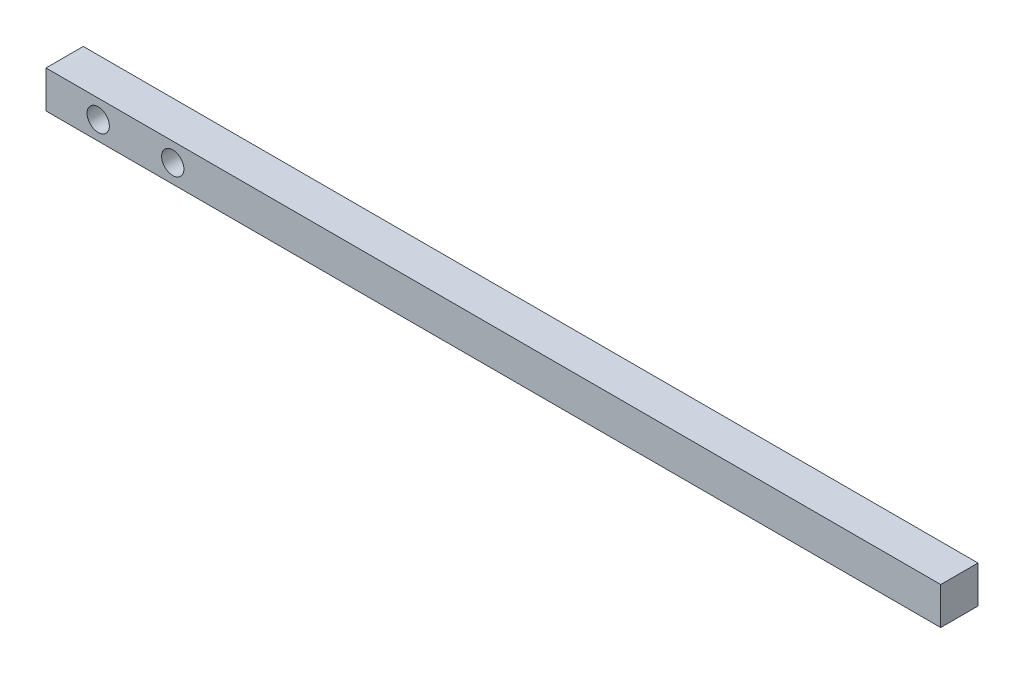
from build123d import *

# Parameters (mm, degrees)
SKETCH1_W             = 152.4
SKETCH1_H             = 6.35
BOSS_EXTRUDE1_DEPTH   = 6.35
F_6_CLEARANCE_HOLE1_D = 3.7973


with BuildPart() as part:
    # Sketch1 → Boss-Extrude1 (new body)
    with BuildSketch(Plane.XY):
        Rectangle(SKETCH1_W, SKETCH1_H)
    extrude(amount=BOSS_EXTRUDE1_DEPTH)

    # #6 Clearance Hole1 (through all)
    with Locations(Plane.XY.offset(6.35)):
        with Locations((-67.31, 0), (-54.61, 0)):
            Hole(F_6_CLEARANCE_HOLE1_D / 2)


solid = part.part
